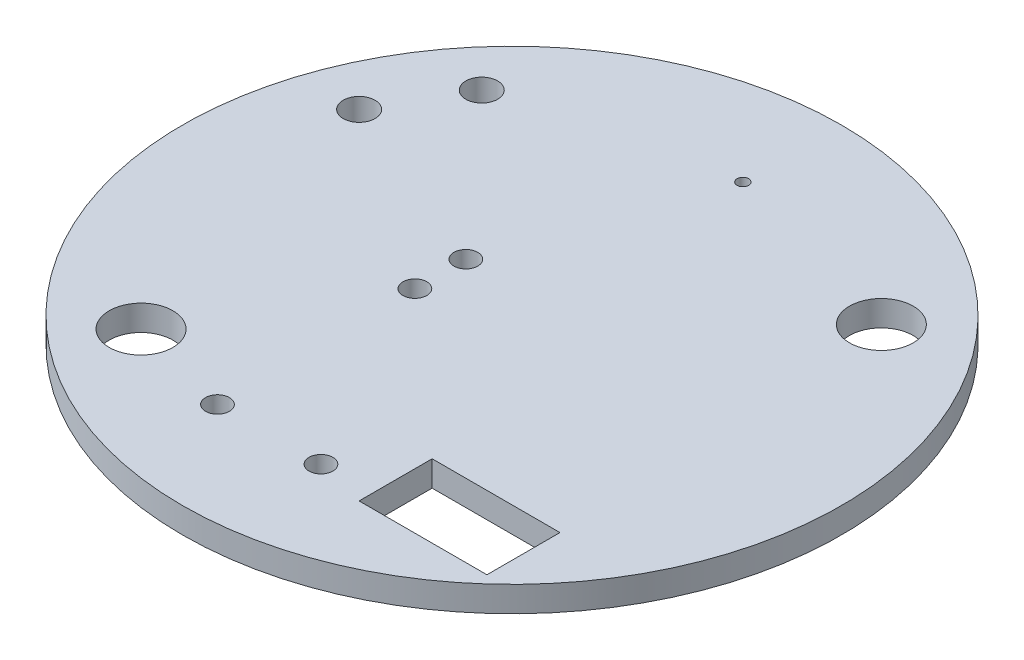
from build123d import *

# Parameters (mm, degrees)
SKETCH_1_R      = 20.7
SKETCH_1_R_2    = 2
SKETCH_1_R_3    = 1
SKETCH_1_R_4    = 0.363900589
SKETCH_1_R_5    = 0.75
SKETCH_1_W      = 8.030309373
SKETCH_1_H      = 4.588748213
EXTRUDE_1_DEPTH = 1.6


with BuildPart() as part:
    # Эскиз1 → Бобышка-Вытянуть1 (new body)
    with BuildSketch(Plane(origin=(0, 0, 0), x_dir=(1, 0, 0), z_dir=(0, 1, 0))):
        Circle(SKETCH_1_R)
        with Locations((12.1, 11.1)):
            Circle(SKETCH_1_R_2, mode=Mode.SUBTRACT)
        with Locations((-10.9, -12.4)):
            Circle(SKETCH_1_R_2, mode=Mode.SUBTRACT)
        with Locations((-16, 6.4)):
            Circle(SKETCH_1_R_3, mode=Mode.SUBTRACT)
        with Locations((-13.2, 11.3)):
            Circle(SKETCH_1_R_3, mode=Mode.SUBTRACT)
        with Locations((0, 14.5)):
            Circle(SKETCH_1_R_4, mode=Mode.SUBTRACT)
        with Locations((-4.5, 1.6)):
            Circle(SKETCH_1_R_5, mode=Mode.SUBTRACT)
        with Locations((-4.5, -1.6)):
            Circle(SKETCH_1_R_5, mode=Mode.SUBTRACT)
        with Locations((-4.4, -14.1)):
            Circle(SKETCH_1_R_5, mode=Mode.SUBTRACT)
        with Locations((2.1, -14.1)):
            Circle(SKETCH_1_R_5, mode=Mode.SUBTRACT)
        with Locations((9.310736127, -12.60613493)):
            Rectangle(SKETCH_1_W, SKETCH_1_H, mode=Mode.SUBTRACT)
    extrude(amount=EXTRUDE_1_DEPTH)


solid = part.part
